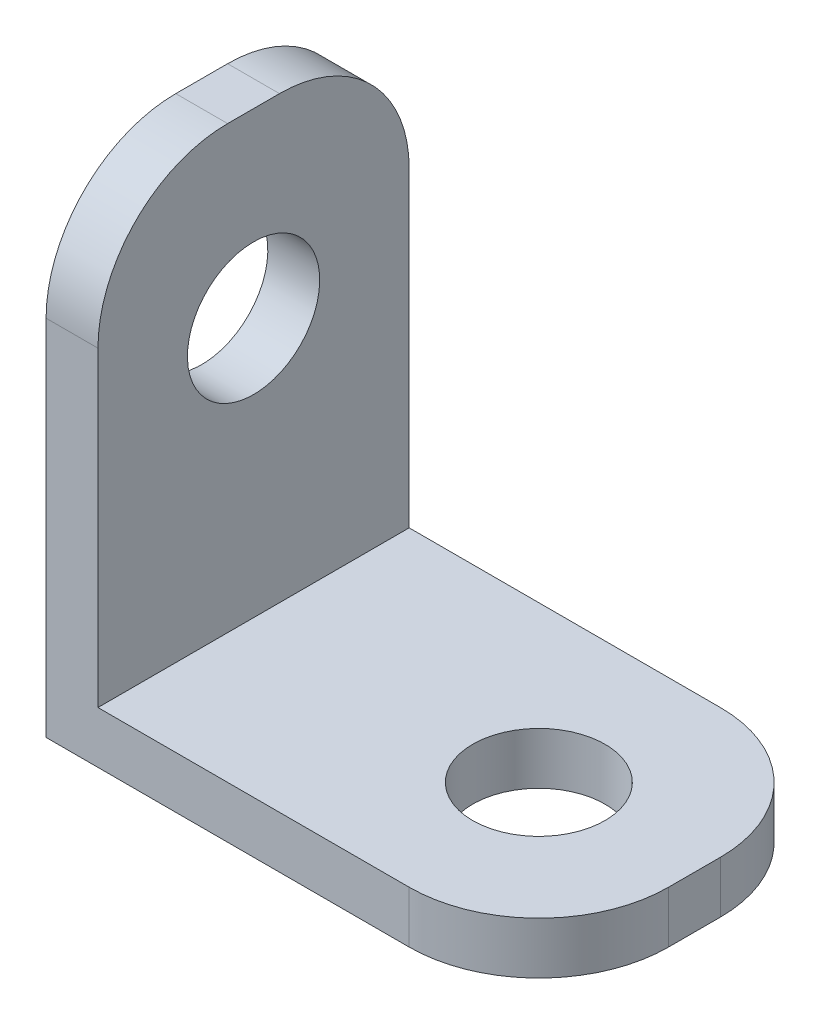
from build123d import *

# Parameters (mm, degrees)
EXTRUDE_1_DEPTH     = 12
SKETCH_2_R          = 2.55
CUT_EXTRUDE_1_DEPTH = 3
SKETCH_3_R          = 2.55
CUT_EXTRUDE_2_DEPTH = 3


with BuildPart() as part:
    # Эскиз1 → Бобышка-Вытянуть1 (new body)
    with BuildSketch(Plane.XY):
        Polygon((0, 0), (0, 19), (2, 19), (2, 2), (19, 2), (19, 0), align=None)
    extrude(amount=EXTRUDE_1_DEPTH)

    # Эскиз2 → Вырез-Вытянуть1 (cut, through all)
    with BuildSketch(Plane(origin=(2, 0, 0), x_dir=(0, 0, -1), z_dir=(1, 0, 0))):
        with Locations((-6, 12)):
            Circle(SKETCH_2_R)
        with BuildLine():
            Line((-12, 14), (-12, 19))
            Line((-12, 19), (-7, 19))
            ThreePointArc((-7, 19), (-10.535533906, 17.535533906), (-12, 14))
        make_face()
        with BuildLine():
            Line((0, 14), (0, 19))
            Line((0, 19), (-5, 19))
            ThreePointArc((-5, 19), (-1.464466094, 17.535533906), (0, 14))
        make_face()
    extrude(amount=-CUT_EXTRUDE_1_DEPTH, mode=Mode.SUBTRACT)

    # Эскиз3 → Вырез-Вытянуть2 (cut, through all)
    with BuildSketch(Plane(origin=(0, 2, 0), x_dir=(1, 0, 0), z_dir=(0, 1, 0))):
        with Locations((13, -6)):
            Circle(SKETCH_3_R)
        with BuildLine():
            Line((14, 0), (19, 0))
            Line((19, 0), (19, -5))
            ThreePointArc((19, -5), (17.535533906, -1.464466094), (14, 0))
        make_face()
        with BuildLine():
            Line((14, -12), (19, -12))
            Line((19, -12), (19, -7))
            ThreePointArc((19, -7), (17.535533906, -10.535533906), (14, -12))
        make_face()
    extrude(amount=-CUT_EXTRUDE_2_DEPTH, mode=Mode.SUBTRACT)


solid = part.part
